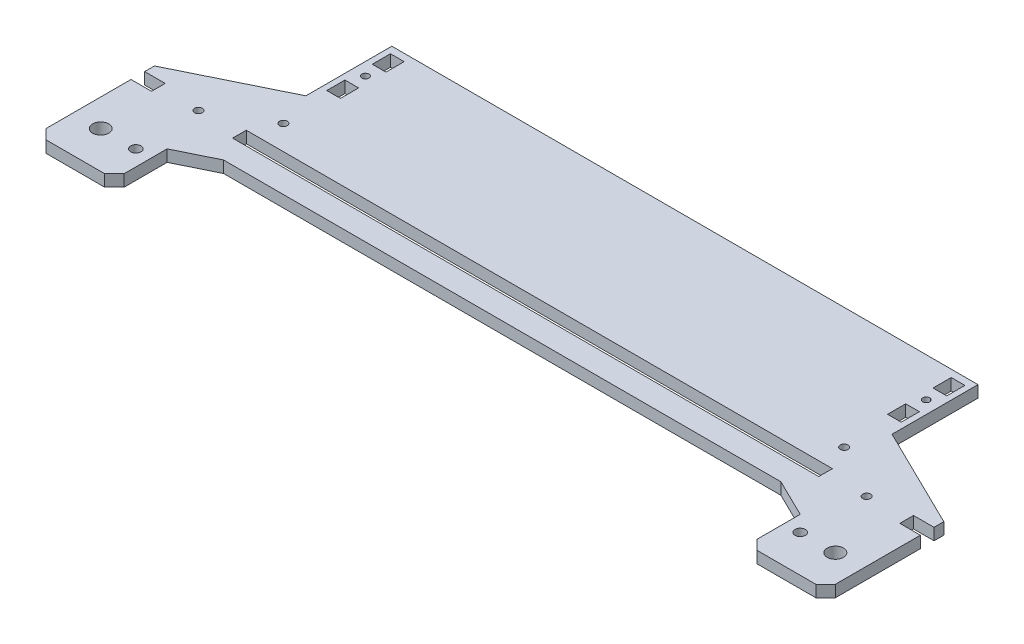
from build123d import *

# Parameters (mm, degrees)
ESQUISSE1_R             = 4.15
ESQUISSE1_R_2           = 2
ESQUISSE1_R_3           = 2.65
BOSS_EXTRU_1_DEPTH      = 6
CHANFREIN1_SIZE         = 5
ESQUISSE3_R             = 1.8
ESQUISSE3_W             = 7
ESQUISSE3_H             = 9.3
ENL_V_MAT_EXTRU_1_DEPTH = 6


with BuildPart() as part:
    # Esquisse1 → Boss.-Extru.1 (new body)
    with BuildSketch(Plane(origin=(0, 0, 0), x_dir=(1, 0, 0), z_dir=(0, 1, 0))):
        Polygon((-150, 0), (-202, -25.5), (-202, -30.5), (-191.5, -30.5), (-191.5, -37.5), (-202, -37.5), (-202, -86), (-162, -86), (-162, -59), (-142.62745098, -49.5), (0, -49.5), (0, -37.5), (-150, -37.5), (-150, -30.5), (0, -30.5), (0, 0), (0, 44), (-150, 44), align=None)
        with Locations((-188, -67)):
            Circle(ESQUISSE1_R, mode=Mode.SUBTRACT)
        with Locations((-171, -34)):
            Circle(ESQUISSE1_R_2, mode=Mode.SUBTRACT)
        with Locations((-170, -67)):
            Circle(ESQUISSE1_R_3, mode=Mode.SUBTRACT)
        with Locations((-143.5, -18)):
            Circle(ESQUISSE1_R_2, mode=Mode.SUBTRACT)
    extrude(amount=BOSS_EXTRU_1_DEPTH)

    # Chanfrein1
    chanfrein1_edges = [part.edges().sort_by_distance(p)[0] for p in [
        (-162, 3, 86),
        (-202, 3, 86),
    ]]
    chamfer(chanfrein1_edges, length=CHANFREIN1_SIZE)

    # Esquisse3 → Enlèv. mat.-Extru.1 (cut)
    with BuildSketch(Plane(origin=(0, 6, 0), x_dir=(1, 0, 0), z_dir=(0, 1, 0))):
        with Locations((-143.5, 24)):
            Circle(ESQUISSE3_R)
        with Locations((-143.5, 35.65)):
            Rectangle(ESQUISSE3_W, ESQUISSE3_H)
        with Locations((-143.5, 12.35)):
            Rectangle(ESQUISSE3_W, ESQUISSE3_H)
    extrude(amount=-ENL_V_MAT_EXTRU_1_DEPTH, mode=Mode.SUBTRACT)

    # Symétrie1: part across plane


with BuildPart() as part_1:
    add(part.part)
    add(part.part.mirror(Plane(origin=(0, 6, 30.5), x_dir=(0, 0, 1), z_dir=(-1, 0, 0))))


solid = part_1.part
